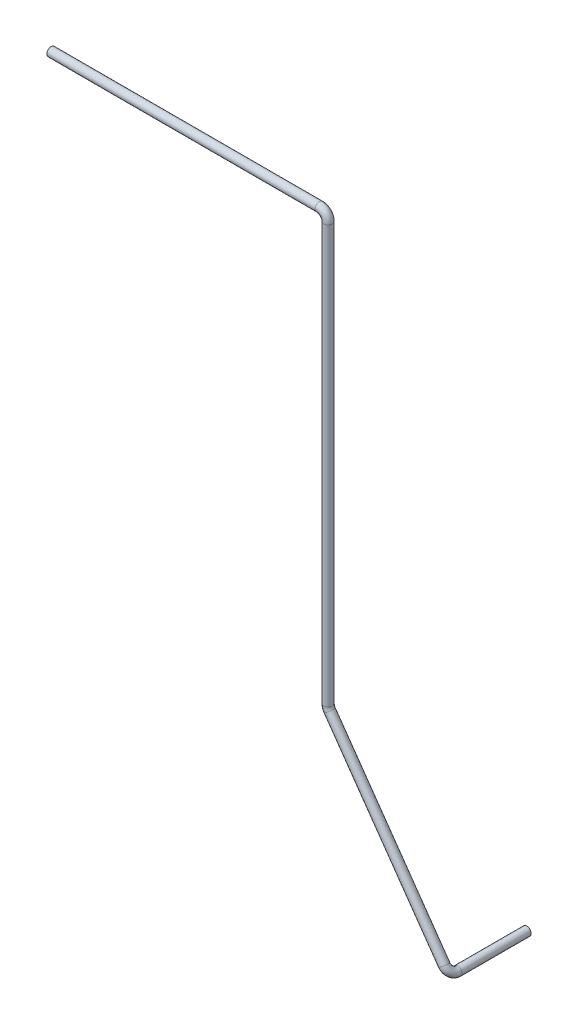
from build123d import *

# Parameters (mm, degrees)
SWEEP_THIN1_PROFILE_R   = 15
SWEEP_THIN1_PROFILE_R_2 = 14


with BuildPart() as part:
    # Sweep-Thin1: sweep along a curve in space
    with BuildLine() as sweep_thin1_path:
        Line((-31243.278100508, -14167.013633935, 40791.837107648), (-30310.46396617, -14167.013633935, 40791.837107648))
        ThreePointArc((-30280.46396617, -14197.013633935, 40791.837107648), (-30289.250762735, -14175.800430499, 40791.837107648), (-30310.46396617, -14167.013633935, 40791.837107648))
        Line((-30280.46396617, -14197.013633935, 40791.837107648), (-30280.46396617, -15648.743313868, 40791.837107648))
        ThreePointArc((-30275.023281313, -15665.972360264, 40791.837107648), (-30279.071477896, -15657.777154295, 40791.837107648), (-30280.46396617, -15648.743313868, 40791.837107648))
        Line((-30275.023281313, -15665.972360264, 40791.837107648), (-29877.026902122, -16233.300248153, 40791.837107648))
        ThreePointArc((-29859.797855726, -16257.859563295, 40761.837107648), (-29864.844126582, -16250.666306431, 40783.050311084), (-29877.026902122, -16233.300248153, 40791.837107648))
        Line((-29859.797855726, -16257.859563295, 40761.837107648), (-29859.797855726, -16257.859563295, 40521.703196056))
    # Sweep-Thin1 profile (on start of the path) → Sweep-Thin1 (sweep)
    with BuildSketch(Plane(origin=(-31243.278100508, -14167.013633935, 40791.837107648), x_dir=(0, 0, 1), z_dir=(1, 0, 0))):
        Circle(SWEEP_THIN1_PROFILE_R)
        Circle(SWEEP_THIN1_PROFILE_R_2, mode=Mode.SUBTRACT)
    sweep(path=sweep_thin1_path.line)


solid = part.part
